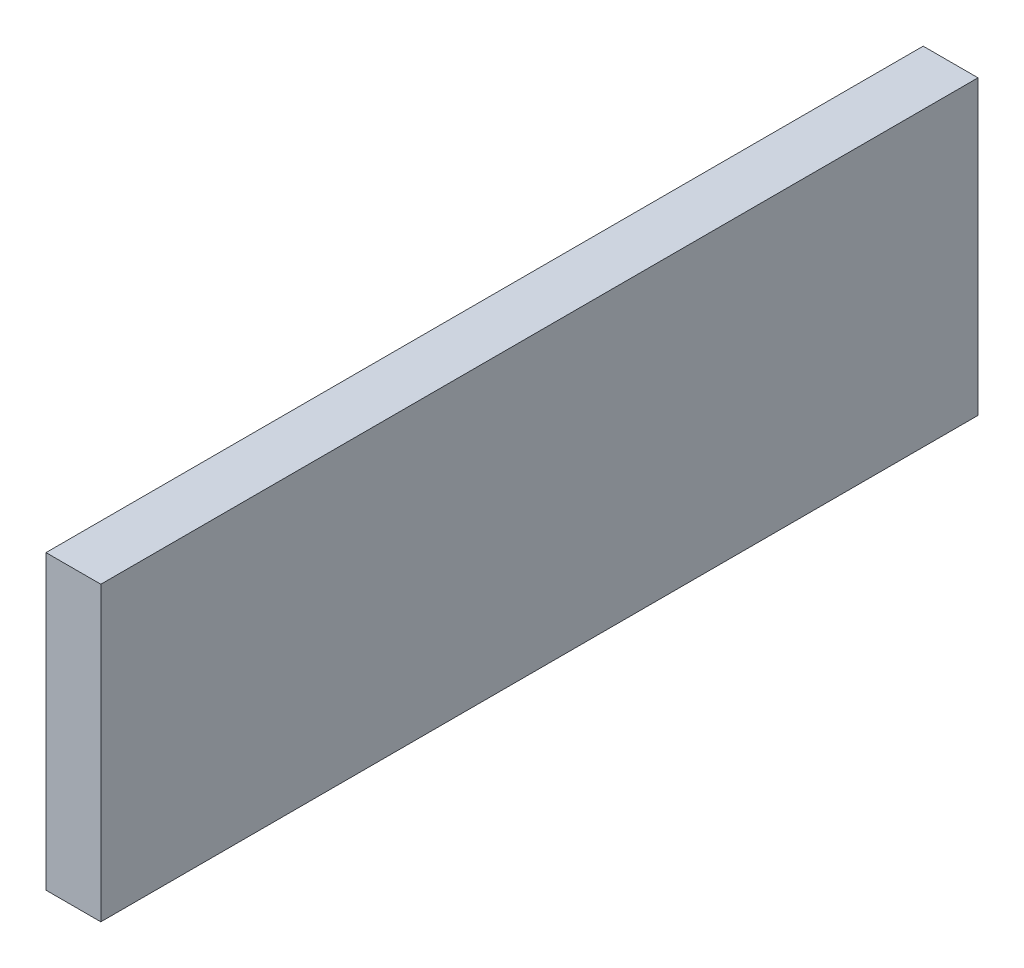
from build123d import *

# Parameters (mm, degrees)
SKETCH1_W           = 304.8
SKETCH1_H           = 101.6
BOSS_EXTRUDE1_DEPTH = 9.525


with BuildPart() as part:
    # Sketch1 → Boss-Extrude1 (new body, symmetric)
    with BuildSketch(Plane(origin=(0, 0, 0), x_dir=(0, 0, -1), z_dir=(1, 0, 0))):
        Rectangle(SKETCH1_W, SKETCH1_H)
    extrude(amount=BOSS_EXTRUDE1_DEPTH, both=True)


solid = part.part
